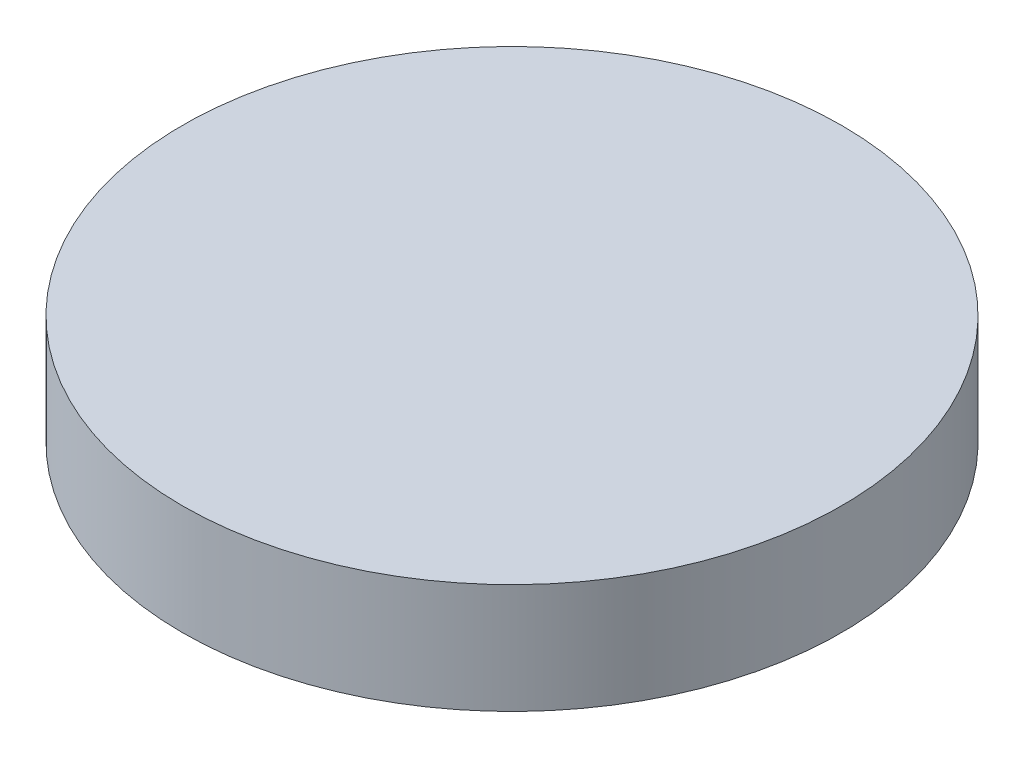
from build123d import *

# Parameters (mm, degrees)
SKETCH1_R           = 30
BOSS_EXTRUDE1_DEPTH = 5
SKETCH2_R           = 2.65
CUT_EXTRUDE1_DEPTH  = 2.6


with BuildPart() as part:
    # Sketch1 → Boss-Extrude1 (new body, symmetric)
    with BuildSketch(Plane(origin=(0, 0, 0), x_dir=(1, 0, 0), z_dir=(0, 1, 0))):
        Circle(SKETCH1_R)
    extrude(amount=BOSS_EXTRUDE1_DEPTH, both=True)

    # Sketch2 → Cut-Extrude1 (cut, symmetric)
    with BuildSketch(Plane(origin=(0, 0, 0), x_dir=(1, 0, 0), z_dir=(0, 1, 0))):
        with Locations((-12.5, 12.5)):
            Circle(SKETCH2_R)
        with Locations((12.5, 12.5)):
            Circle(SKETCH2_R)
        with Locations((12.5, -12.5)):
            Circle(SKETCH2_R)
        with Locations((-12.5, -12.5)):
            Circle(SKETCH2_R)
    extrude(amount=CUT_EXTRUDE1_DEPTH, both=True, mode=Mode.SUBTRACT)


solid = part.part
